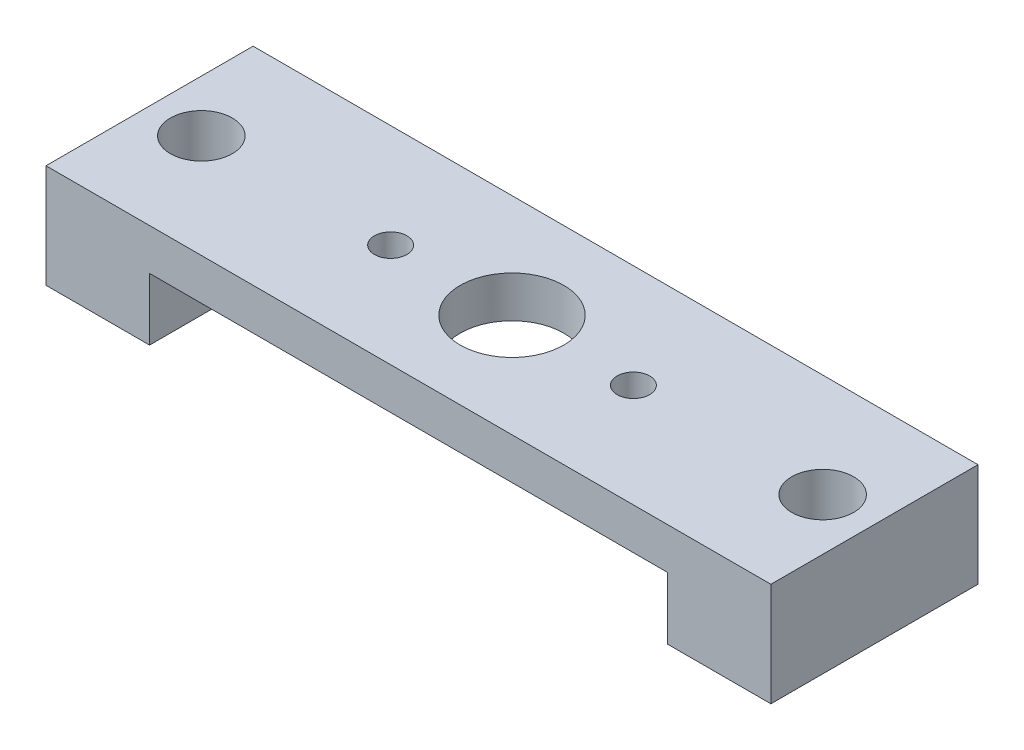
from build123d import *

# Parameters (mm, degrees)
SKETCH1_W                   = 44.45
SKETCH1_H                   = 12.7
BOSS_EXTRUDE1_DEPTH         = 2.54
SKETCH2_W                   = 6.35
SKETCH2_H                   = 12.7
BOSS_EXTRUDE2_DEPTH         = 3.81
F_6_CLEARANCE_HOLE1_D       = 3.7973
F_3_48_TAPPED_HOLE1_D       = 1.9939
F_1_4_0_25_DIAMETER_HOLE1_D = 6.35


with BuildPart() as part:
    # Sketch1 → Boss-Extrude1 (new body)
    with BuildSketch(Plane(origin=(0, 0, 0), x_dir=(1, 0, 0), z_dir=(0, 1, 0))):
        with Locations((22.225, 6.35)):
            Rectangle(SKETCH1_W, SKETCH1_H)
    extrude(amount=BOSS_EXTRUDE1_DEPTH)

    # Sketch2 → Boss-Extrude2 (add)
    with BuildSketch(Plane.XZ):
        with Locations((3.175, -6.35)):
            Rectangle(SKETCH2_W, SKETCH2_H)
        with Locations((41.275, -6.35)):
            Rectangle(SKETCH2_W, SKETCH2_H)
    extrude(amount=BOSS_EXTRUDE2_DEPTH)

    # #6 Clearance Hole1 (through all)
    with Locations(Plane(origin=(0, 2.54, 0), x_dir=(1, 0, 0), z_dir=(0, 1, 0))):
        with Locations((3.175, 6.35), (41.275, 6.35)):
            Hole(F_6_CLEARANCE_HOLE1_D / 2)

    # #3-48 Tapped Hole1 (through all)
    with Locations(Plane(origin=(0, 2.54, 0), x_dir=(1, 0, 0), z_dir=(0, 1, 0))):
        with Locations((14.7828, 6.35), (29.6672, 6.35)):
            Hole(F_3_48_TAPPED_HOLE1_D / 2)

    # 1/4 (0.25) Diameter Hole1 (through all)
    with Locations(Plane(origin=(0, 2.54, 0), x_dir=(1, 0, 0), z_dir=(0, 1, 0))):
        with Locations((22.225, 6.35)):
            Hole(F_1_4_0_25_DIAMETER_HOLE1_D / 2)


solid = part.part
